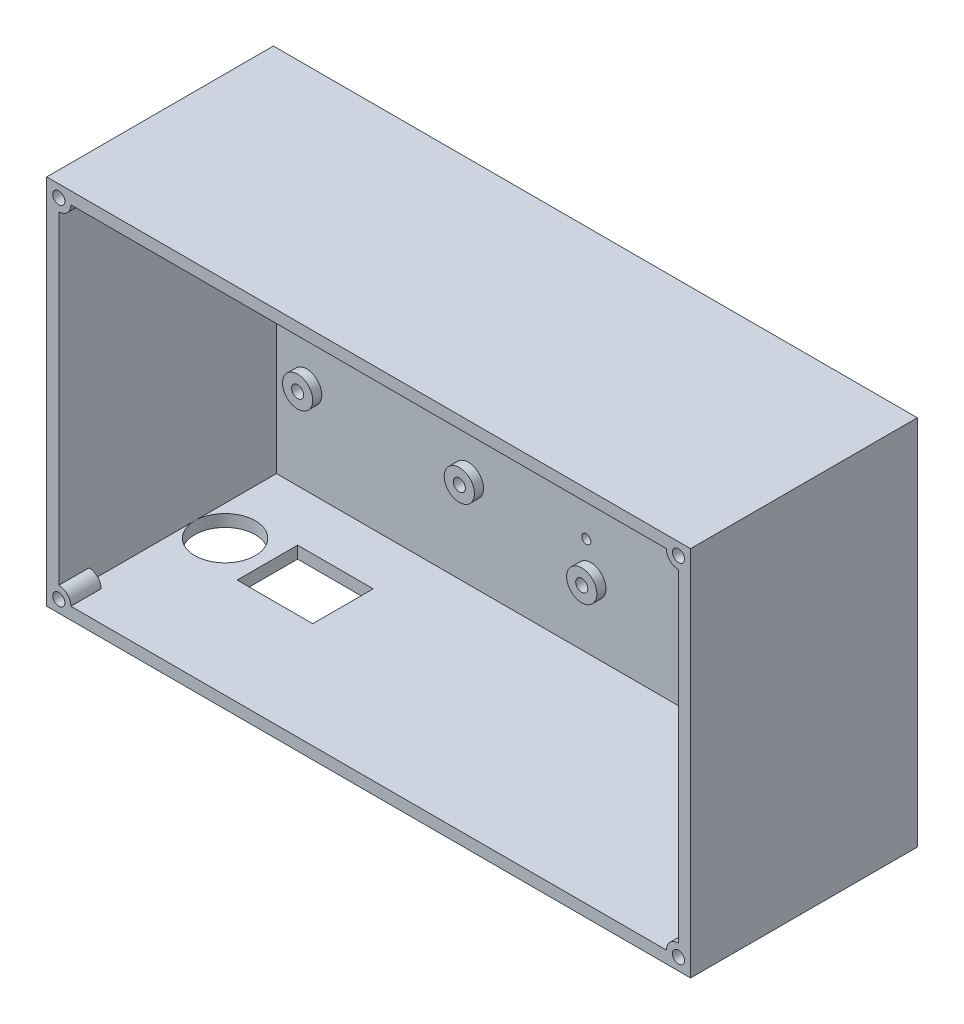
from build123d import *

# Parameters (mm, degrees)
SKETCH1_W                           = 205
SKETCH1_H                           = 115
BOSS_EXTRUDE1_DEPTH                 = 3
SKETCH2_R                           = 5
SKETCH2_R_2                         = 2
BOSS_EXTRUDE2_DEPTH                 = 3
SKETCH3_R                           = 5
SKETCH3_R_2                         = 2
BOSS_EXTRUDE3_DEPTH                 = 3
SKETCH5_W                           = 213
SKETCH5_H                           = 123
SKETCH5_W_2                         = 205
SKETCH5_H_2                         = 115
BOSS_EXTRUDE4_DEPTH                 = 75
F_3_0MM_CLEARANCE_DOWEL_HOLE1_D     = 3
F_3_0MM_CLEARANCE_DOWEL_HOLE1_DEPTH = 30
F_3_0MM_CLEARANCE_DOWEL_HOLE1_TIP   = 0.901290929
SKETCH10_W                          = 25
SKETCH10_H                          = 20
CUT_EXTRUDE1_DEPTH                  = 4
SKETCH11_R                          = 10
CUT_EXTRUDE2_DEPTH                  = 4
SKETCH12_R                          = 4
SKETCH12_R_2                        = 2
BOSS_EXTRUDE5_DEPTH                 = 10
SKETCH13_R                          = 2
CUT_EXTRUDE3_DEPTH                  = 10


with BuildPart() as part:
    # Sketch1 → Boss-Extrude1 (new body)
    with BuildSketch(Plane.XY):
        Rectangle(SKETCH1_W, SKETCH1_H)
    extrude(amount=BOSS_EXTRUDE1_DEPTH)

    # Sketch2 → Boss-Extrude2 (add)
    with BuildSketch(Plane.XY.offset(3)):
        with Locations((-92.5, 32.5)):
            Circle(SKETCH2_R)
        with Locations((-92.5, 32.5)):
            Circle(SKETCH2_R_2, mode=Mode.SUBTRACT)
        with Locations((-92.5, -27.5)):
            Circle(SKETCH2_R)
        with Locations((-92.5, -27.5)):
            Circle(SKETCH2_R_2, mode=Mode.SUBTRACT)
        with Locations((-39, 32.5)):
            Circle(SKETCH2_R)
        with Locations((-39, 32.5)):
            Circle(SKETCH2_R_2, mode=Mode.SUBTRACT)
        with Locations((-39, -27.5)):
            Circle(SKETCH2_R)
        with Locations((-39, -27.5)):
            Circle(SKETCH2_R_2, mode=Mode.SUBTRACT)
    extrude(amount=BOSS_EXTRUDE2_DEPTH)

    # Sketch3 → Boss-Extrude3 (add)
    with BuildSketch(Plane.XY.offset(3)):
        with Locations((1.5, 40)):
            Circle(SKETCH3_R)
        with Locations((1.5, 40)):
            Circle(SKETCH3_R_2, mode=Mode.SUBTRACT)
        with Locations((82.5, -36)):
            Circle(SKETCH3_R)
        with Locations((82.5, -36)):
            Circle(SKETCH3_R_2, mode=Mode.SUBTRACT)
        with Locations((82.5, 40)):
            Circle(SKETCH3_R)
        with Locations((82.5, 40)):
            Circle(SKETCH3_R_2, mode=Mode.SUBTRACT)
        with Locations((1.5, -36)):
            Circle(SKETCH3_R)
        with Locations((1.5, -36)):
            Circle(SKETCH3_R_2, mode=Mode.SUBTRACT)
    extrude(amount=BOSS_EXTRUDE3_DEPTH)

    # Sketch5 → Boss-Extrude4 (add)
    with BuildSketch(Plane(origin=(0, 0, 0), x_dir=(-1, 0, 0), z_dir=(0, 0, -1))):
        Rectangle(SKETCH5_W, SKETCH5_H)
        Rectangle(SKETCH5_W_2, SKETCH5_H_2, mode=Mode.SUBTRACT)
    extrude(amount=-BOSS_EXTRUDE4_DEPTH)

    # Ø3.0mm Clearance Dowel Hole1
    with Locations(Plane.XY.offset(3)):
        with Locations((0, 25), (0, -25)):
            Hole(F_3_0MM_CLEARANCE_DOWEL_HOLE1_D / 2, depth=F_3_0MM_CLEARANCE_DOWEL_HOLE1_DEPTH)
            with Locations((0, 0, -(F_3_0MM_CLEARANCE_DOWEL_HOLE1_DEPTH + F_3_0MM_CLEARANCE_DOWEL_HOLE1_TIP / 2))):  # 118° drill point
                Cone(0, F_3_0MM_CLEARANCE_DOWEL_HOLE1_D / 2, F_3_0MM_CLEARANCE_DOWEL_HOLE1_TIP, mode=Mode.SUBTRACT)

    # Sketch10 → Cut-Extrude1 (cut)
    with BuildSketch(Plane.XZ.offset(61.5)):
        with Locations((-66, 30)):
            Rectangle(SKETCH10_W, SKETCH10_H)
    extrude(amount=-CUT_EXTRUDE1_DEPTH, mode=Mode.SUBTRACT)

    # Sketch11 → Cut-Extrude2 (cut)
    with BuildSketch(Plane.XZ.offset(61.5)):
        with Locations((-92.5, 30)):
            Circle(SKETCH11_R)
    extrude(amount=-CUT_EXTRUDE2_DEPTH, mode=Mode.SUBTRACT)

    # Sketch12 → Boss-Extrude5 (add)
    with BuildSketch(Plane.XY.offset(75)):
        with Locations((102.5, -57.5)):
            Circle(SKETCH12_R)
        with Locations((102.5, -57.5)):
            Circle(SKETCH12_R_2, mode=Mode.SUBTRACT)
        with Locations((102.5, 57.5)):
            Circle(SKETCH12_R)
        with Locations((-102.5, 57.5)):
            Circle(SKETCH12_R)
        with Locations((-102.5, -57.5)):
            Circle(SKETCH12_R)
    extrude(amount=-BOSS_EXTRUDE5_DEPTH)

    # Sketch13 → Cut-Extrude3 (cut)
    with BuildSketch(Plane.XY.offset(75)):
        with Locations((102.5, -57.5)):
            Circle(SKETCH13_R)
        with Locations((102.5, 57.5)):
            Circle(SKETCH13_R)
        with Locations((-102.5, 57.5)):
            Circle(SKETCH13_R)
        with Locations((-102.5, -57.5)):
            Circle(SKETCH13_R)
    extrude(amount=-CUT_EXTRUDE3_DEPTH, mode=Mode.SUBTRACT)


solid = part.part
